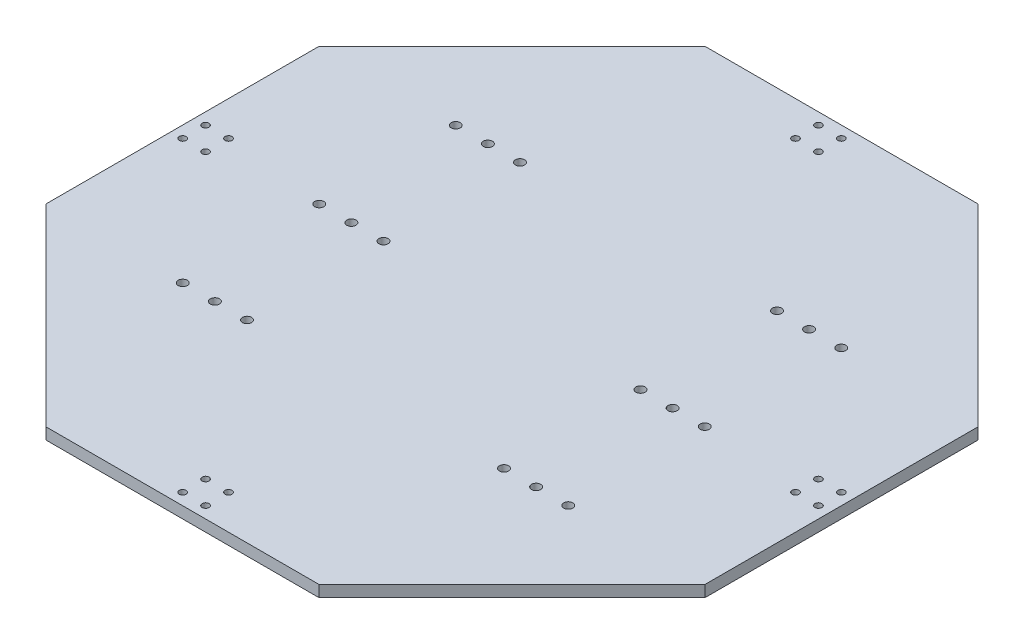
from build123d import *

# Parameters (mm, degrees)
SKETCH_1_R          = 1.5
EXTRUDE_1_DEPTH     = 5
SKETCH_2_R          = 2
CUT_EXTRUDE_1_DEPTH = 10


with BuildPart() as part:
    # 스케치1 → 보스-돌출1 (new body)
    with BuildSketch(Plane(origin=(0, 0, 0), x_dir=(1, 0, 0), z_dir=(0, 1, 0))):
        Polygon((59.481067557, -143.6), (143.6, -59.481067557), (143.6, 59.481067557), (59.481067557, 143.6), (-59.481067557, 143.6), (-143.6, 59.481067557), (-143.6, -59.481067557), (-59.481067557, -143.6), align=None)
        with Locations((-5, 138.54)):
            Circle(SKETCH_1_R, mode=Mode.SUBTRACT)
        with Locations((-5, 128.54)):
            Circle(SKETCH_1_R, mode=Mode.SUBTRACT)
        with Locations((5, 128.54)):
            Circle(SKETCH_1_R, mode=Mode.SUBTRACT)
        with Locations((5, 138.54)):
            Circle(SKETCH_1_R, mode=Mode.SUBTRACT)
        with Locations((138.54, 5)):
            Circle(SKETCH_1_R, mode=Mode.SUBTRACT)
        with Locations((128.54, 5)):
            Circle(SKETCH_1_R, mode=Mode.SUBTRACT)
        with Locations((128.54, -5)):
            Circle(SKETCH_1_R, mode=Mode.SUBTRACT)
        with Locations((138.54, -5)):
            Circle(SKETCH_1_R, mode=Mode.SUBTRACT)
        with Locations((5, -138.54)):
            Circle(SKETCH_1_R, mode=Mode.SUBTRACT)
        with Locations((5, -128.54)):
            Circle(SKETCH_1_R, mode=Mode.SUBTRACT)
        with Locations((-5, -128.54)):
            Circle(SKETCH_1_R, mode=Mode.SUBTRACT)
        with Locations((-5, -138.54)):
            Circle(SKETCH_1_R, mode=Mode.SUBTRACT)
        with Locations((-138.54, -5)):
            Circle(SKETCH_1_R, mode=Mode.SUBTRACT)
        with Locations((-128.54, -5)):
            Circle(SKETCH_1_R, mode=Mode.SUBTRACT)
        with Locations((-128.54, 5)):
            Circle(SKETCH_1_R, mode=Mode.SUBTRACT)
        with Locations((-138.54, 5)):
            Circle(SKETCH_1_R, mode=Mode.SUBTRACT)
    extrude(amount=EXTRUDE_1_DEPTH)

    # 스케치2 → 컷-돌출1 (cut)
    with BuildSketch(Plane(origin=(0, 5, 0), x_dir=(1, 0, 0), z_dir=(0, 1, 0))):
        with Locations((-56, 0)):
            Circle(SKETCH_2_R)
        with Locations((-56, 59.482135114)):
            Circle(SKETCH_2_R)
        with Locations((-56, -59.482135114)):
            Circle(SKETCH_2_R)
        with Locations((70, 0)):
            Circle(SKETCH_2_R)
        with Locations((70, 59.482135114)):
            Circle(SKETCH_2_R)
        with Locations((70, -59.482135114)):
            Circle(SKETCH_2_R)
        with Locations((-70, -59.482135114)):
            Circle(SKETCH_2_R)
        with Locations((-70, 59.482135114)):
            Circle(SKETCH_2_R)
        with Locations((-70, 0)):
            Circle(SKETCH_2_R)
        with Locations((56, -59.482135114)):
            Circle(SKETCH_2_R)
        with Locations((56, 59.482135114)):
            Circle(SKETCH_2_R)
        with Locations((56, 0)):
            Circle(SKETCH_2_R)
        with Locations((-84, 0)):
            Circle(SKETCH_2_R)
        with Locations((-84, 59.482135114)):
            Circle(SKETCH_2_R)
        with Locations((-84, -59.482135114)):
            Circle(SKETCH_2_R)
        with Locations((84, -59.482135114)):
            Circle(SKETCH_2_R)
        with Locations((84, 59.482135114)):
            Circle(SKETCH_2_R)
        with Locations((84, 0)):
            Circle(SKETCH_2_R)
    extrude(amount=-CUT_EXTRUDE_1_DEPTH, mode=Mode.SUBTRACT)


solid = part.part
